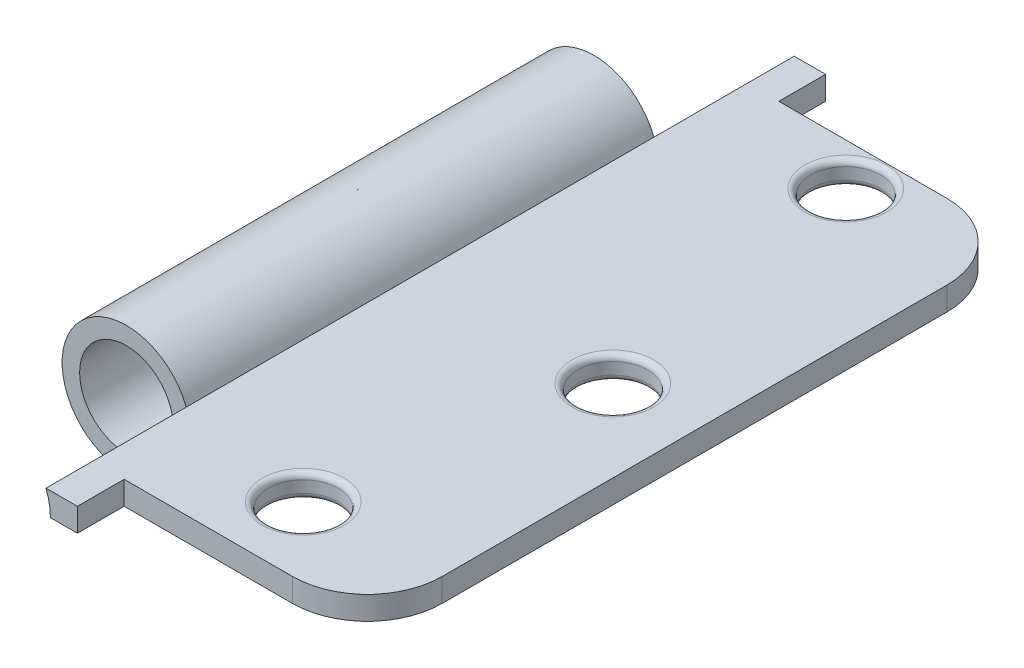
from build123d import *

# Parameters (mm, degrees)
SKETCH1_R                = 4.7625
BOSS_EXTRUDE1_DEPTH      = 3.175
SKETCH2_R                = 6.35
BOSS_EXTRUDE2_DEPTH      = 6.35
BOSS_EXTRUDE2_DEPTH_BACK = 95.25
SKETCH4_R                = 8.73125
CUT_EXTRUDE3_DEPTH       = 19.05
SKETCH5_R                = 8.73125
CUT_EXTRUDE4_DEPTH       = 19.05
FILLET1_R                = 0.79375
SKETCH6_W                = 0.4134866
SKETCH6_H                = 3.175
BOSS_EXTRUDE3_DEPTH      = 101.6


with BuildPart() as part:
    # Sketch1 → Boss-Extrude1 (new body)
    with BuildSketch(Plane(origin=(0, 0, 0), x_dir=(1, 0, 0), z_dir=(0, 1, 0))):
        with BuildLine():
            Line((0, 44.45), (0, -44.45))
            Line((0, -44.45), (23.273512, -44.45))
            ThreePointArc((23.273512, -44.45), (30.457716897, -41.474204897), (33.433512, -34.29))
            Line((33.433512, -34.29), (33.433512, 34.29))
            ThreePointArc((33.433512, 34.29), (30.457716897, 41.474204897), (23.273512, 44.45))
            Line((23.273512, 44.45), (0, 44.45))
        make_face()
        with Locations((15.209012, 38.735)):
            Circle(SKETCH1_R, mode=Mode.SUBTRACT)
        with Locations((15.209012, -34.925)):
            Circle(SKETCH1_R, mode=Mode.SUBTRACT)
        with Locations((22.321012, 0)):
            Circle(SKETCH1_R, mode=Mode.SUBTRACT)
    extrude(amount=BOSS_EXTRUDE1_DEPTH)

    # Sketch2 → Boss-Extrude2 (add, two sides)
    with BuildSketch(Plane.XY.offset(44.45)) as boss_extrude2_sk:
        with BuildLine():
            Line((0, 0), (-3.250954467, 0))
            ThreePointArc((-3.250954467, 0), (-20.562720138, -1.615387688), (-3.848687297, 3.175))
            Line((-3.848687297, 3.175), (0, 3.175))
            Line((0, 3.175), (0, 0))
        make_face()
        with Locations((-11.982204467, 0)):
            Circle(SKETCH2_R, mode=Mode.SUBTRACT)
    extrude(amount=BOSS_EXTRUDE2_DEPTH)
    extrude(boss_extrude2_sk.sketch, amount=-BOSS_EXTRUDE2_DEPTH_BACK)

    # Sketch4 → Cut-Extrude3 (cut)
    with BuildSketch(Plane.XY.offset(50.8)):
        with Locations((-11.982204467, 0)):
            Circle(SKETCH4_R)
    extrude(amount=-CUT_EXTRUDE3_DEPTH, mode=Mode.SUBTRACT)

    # Sketch5 → Cut-Extrude4 (cut)
    with BuildSketch(Plane(origin=(0, 0, -50.8), x_dir=(-1, 0, 0), z_dir=(0, 0, -1))):
        with Locations((11.982204467, 0)):
            Circle(SKETCH5_R)
    extrude(amount=-CUT_EXTRUDE4_DEPTH, mode=Mode.SUBTRACT)

    # Fillet1
    fillet1_edges = [part.edges().sort_by_distance(p)[0] for p in [
        (10.446512, 0, -38.735),
        (10.446512, 3.175, -38.735),
        (10.446512, 0, 34.925),
        (10.446512, 3.175, 34.925),
        (17.558512, 0, 0),
        (17.558512, 3.175, 0),
    ]]
    fillet(fillet1_edges, radius=FILLET1_R)

    # Sketch6 → Boss-Extrude3 (add)
    with BuildSketch(Plane.XY.offset(50.8)):
        with Locations((0.2067433, 1.5875)):
            Rectangle(SKETCH6_W, SKETCH6_H)
    extrude(amount=-BOSS_EXTRUDE3_DEPTH)


solid = part.part
